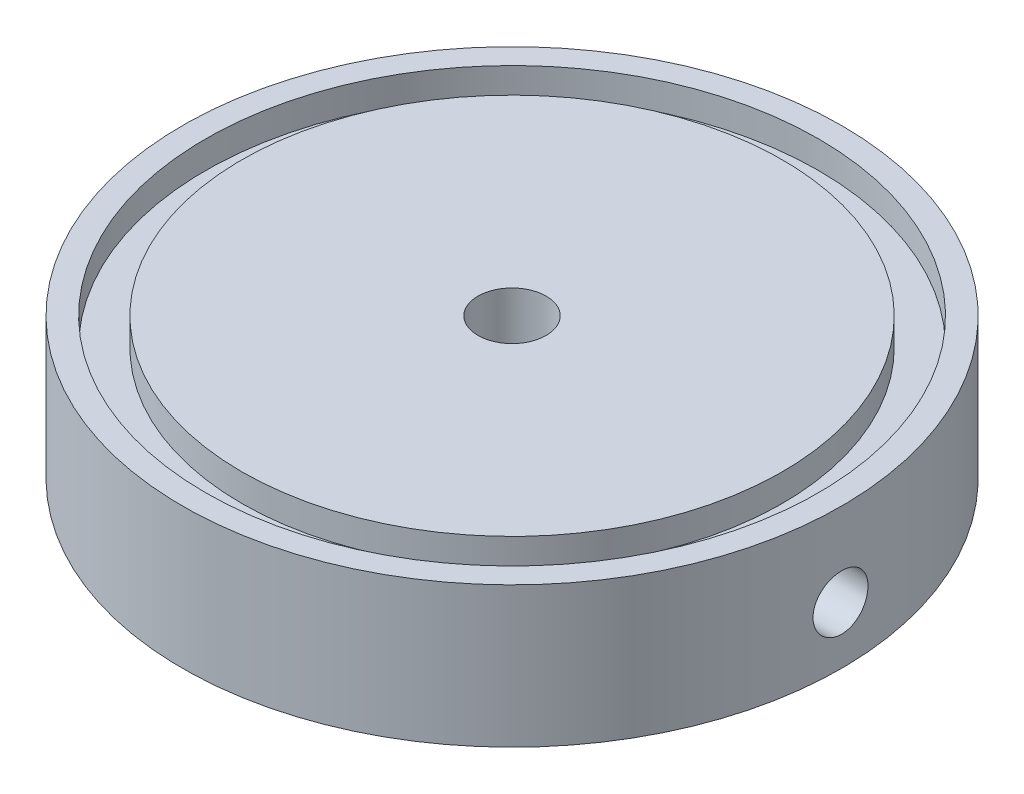
from build123d import *

# Parameters (mm, degrees)
SKETCH2_R          = 1.7272
CUT_EXTRUDE1_DEPTH = 55.599698738
SKETCH3_R          = 35.433
SKETCH3_R_2        = 31.242
CUT_EXTRUDE2_DEPTH = 3.175
SKETCH4_R          = 1.03251
CUT_EXTRUDE3_DEPTH = 3.175
CIRPATTERN1_COUNT  = 9
SKETCH5_R          = 3.175
CUT_EXTRUDE4_DEPTH = 9.525
FILLET1_R          = 1.27


with BuildPart() as part:
    # Sketch1 → Revolve1 (revolve)
    with BuildSketch(Plane.XY):
        with BuildLine():
            Line((3.94335, 7.43458), (38.1, 7.43458))
            Line((38.1, 7.43458), (38.1, -8.82142))
            Line((38.1, -8.82142), (22.6695, -8.82142))
            Line((22.6695, -8.82142), (22.6695, -7.8105))
            Line((22.6695, -7.8105), (21.1455, -7.8105))
            Line((21.1455, -7.8105), (21.1455, -8.8265))
            Line((21.1455, -8.8265), (10.9855, -8.8265))
            Line((10.9855, -8.8265), (10.9855, -6.391948453))
            ThreePointArc((10.9855, -6.391948453), (10.570616467, -5.000733157), (9.4615, -4.064))
            Line((9.4615, -4.064), (3.94335, 0))
            Line((3.94335, 0), (3.94335, 7.43458))
        make_face()
    revolve(axis=Axis((0, 101.60464546, 0), (0, 1, 0)))

    # Sketch2 → Cut-Extrude1 (cut, through all)
    with BuildSketch(Plane(origin=(0, 0, 0), x_dir=(0, 0, -1), z_dir=(1, 0, 0))):
        with Locations((0, -2.21742)):
            Circle(SKETCH2_R)
    extrude(amount=CUT_EXTRUDE1_DEPTH, mode=Mode.SUBTRACT)

    # Sketch3 → Cut-Extrude2 (cut)
    with BuildSketch(Plane(origin=(0, 7.43458, 0), x_dir=(1, 0, 0), z_dir=(0, 1, 0))):
        Circle(SKETCH3_R)
        Circle(SKETCH3_R_2, mode=Mode.SUBTRACT)
    extrude(amount=-CUT_EXTRUDE2_DEPTH, mode=Mode.SUBTRACT)

    # Sketch4 → Cut-Extrude3 (cut)
    with BuildSketch(Plane(origin=(0, -8.82142, 0), x_dir=(-1, 0, 0), z_dir=(0, -1, 0))):
        with Locations((-13.97, 24.196749782)):
            Circle(SKETCH4_R)
    cut_extrude3 = extrude(amount=-CUT_EXTRUDE3_DEPTH, mode=Mode.SUBTRACT)

    # CirPattern1: Cut-Extrude3 ×9 about axis
    cirpattern1_axis = Axis((0, 7.43458, 0), (0, -1, 0))
    for i in range(1, CIRPATTERN1_COUNT):
        add(cut_extrude3.rotate(cirpattern1_axis, i * 360 / CIRPATTERN1_COUNT), mode=Mode.SUBTRACT)

    # Sketch5 → Cut-Extrude4 (cut)
    with BuildSketch(Plane(origin=(38.1, 0, 0), x_dir=(0, 0, -1), z_dir=(1, 0, 0))):
        with Locations((0, -2.21742)):
            Circle(SKETCH5_R)
    extrude(amount=-CUT_EXTRUDE4_DEPTH, mode=Mode.SUBTRACT)

    # Fillet1
    fillet1_edges = [part.edges().sort_by_distance(p)[0] for p in [
        (-3.94335, 0, 0),
    ]]
    fillet(fillet1_edges, radius=FILLET1_R)


solid = part.part
